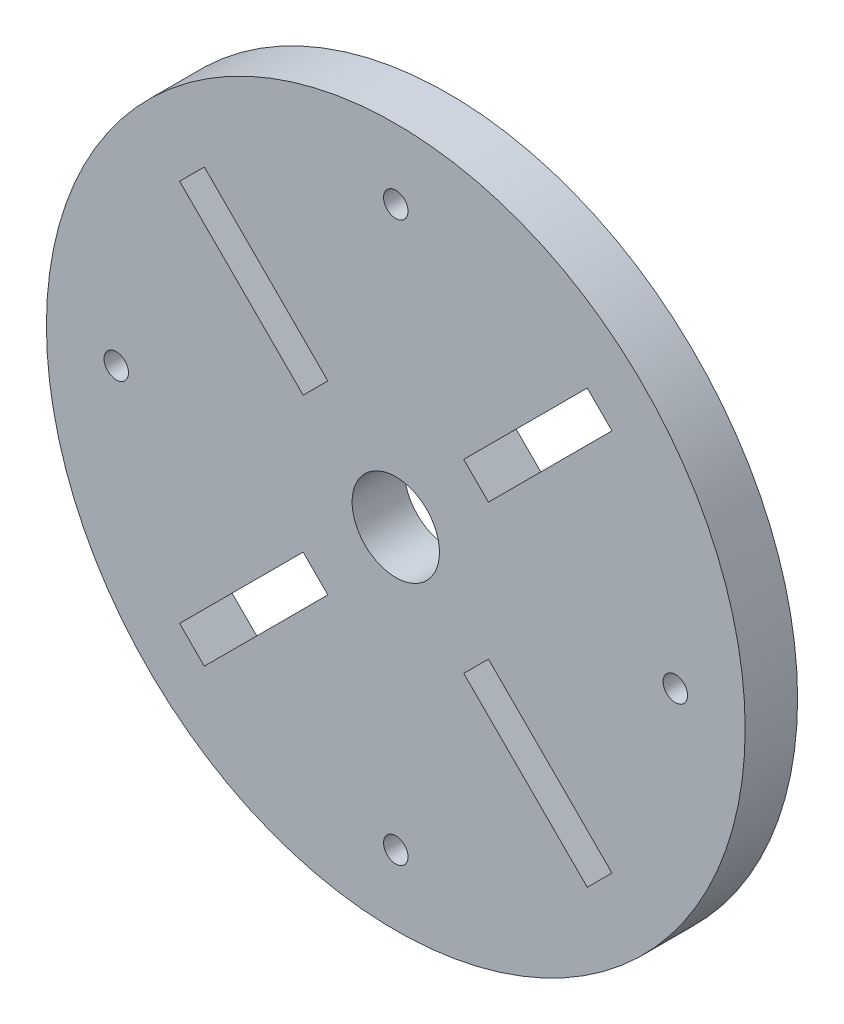
from build123d import *

# Parameters (mm, degrees)
SKETCH_1_R               = 20
EXTRUDE_1_DEPTH          = 3
SKETCH_2_R               = 0.7
CUT_EXTRUDE_1_DEPTH      = 3
PATTERN_CIRCULAR_2_COUNT = 4
SKETCH_4_R               = 2.5
CUT_EXTRUDE_3_DEPTH      = 3
CUT_EXTRUDE_4_DEPTH      = 3
PATTERN_CIRCULAR_4_COUNT = 4


with BuildPart() as part:
    # ｽｹｯﾁ1 → ﾎﾞｽ - 押し出し1 (new body)
    with BuildSketch(Plane.XY):
        Circle(SKETCH_1_R)
    extrude(amount=EXTRUDE_1_DEPTH)

    # ｽｹｯﾁ2 → ｶｯﾄ - 押し出し1 (cut)
    with BuildSketch(Plane.XY.offset(3)):
        with Locations((0, 16)):
            Circle(SKETCH_2_R)
    cut_extrude_1 = extrude(amount=-CUT_EXTRUDE_1_DEPTH, mode=Mode.SUBTRACT)

    # 円形ﾊﾟﾀｰﾝ2: ｶｯﾄ - 押し出し1 ×4 about axis
    pattern_circular_2_axis = Axis((0, 0, 0), (0, 0, 1))
    for i in range(1, PATTERN_CIRCULAR_2_COUNT):
        add(cut_extrude_1.rotate(pattern_circular_2_axis, i * 360 / PATTERN_CIRCULAR_2_COUNT), mode=Mode.SUBTRACT)

    # ｽｹｯﾁ4 → ｶｯﾄ - 押し出し3 (cut)
    with BuildSketch(Plane.XY.offset(3)):
        Circle(SKETCH_4_R)
    extrude(amount=-CUT_EXTRUDE_3_DEPTH, mode=Mode.SUBTRACT)

    # ｽｹｯﾁ5 → ｶｯﾄ - 押し出し4 (cut)
    with BuildSketch(Plane.XY.offset(3)):
        Polygon((4.596194078, 4.596194078), (3.889087297, 5.303300859), (10.960155108, 12.374368671), (12.374368671, 10.960155108), (5.303300859, 3.889087297), align=None)
    cut_extrude_4 = extrude(amount=-CUT_EXTRUDE_4_DEPTH, mode=Mode.SUBTRACT)

    # 円形ﾊﾟﾀｰﾝ4: ｶｯﾄ - 押し出し4 ×4 about axis
    pattern_circular_4_axis = Axis((0, 0, 0), (0, 0, 1))
    for i in range(1, PATTERN_CIRCULAR_4_COUNT):
        add(cut_extrude_4.rotate(pattern_circular_4_axis, i * 360 / PATTERN_CIRCULAR_4_COUNT), mode=Mode.SUBTRACT)


solid = part.part
